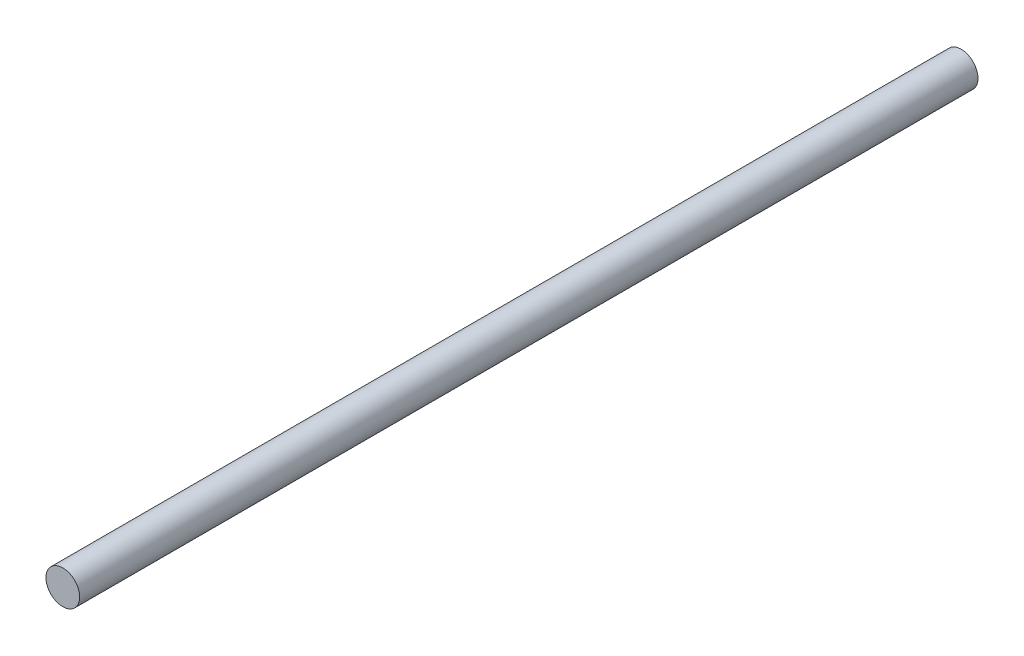
from build123d import *

# Parameters (mm, degrees)
SKIZZE1_R                       = 1.5
AUFSATZ_LINEAR_AUSTRAGEN1_DEPTH = 80


with BuildPart() as part:
    # Skizze1 → Aufsatz-Linear austragen1 (new body)
    with BuildSketch(Plane.XY):
        Circle(SKIZZE1_R)
    extrude(amount=AUFSATZ_LINEAR_AUSTRAGEN1_DEPTH)


solid = part.part
